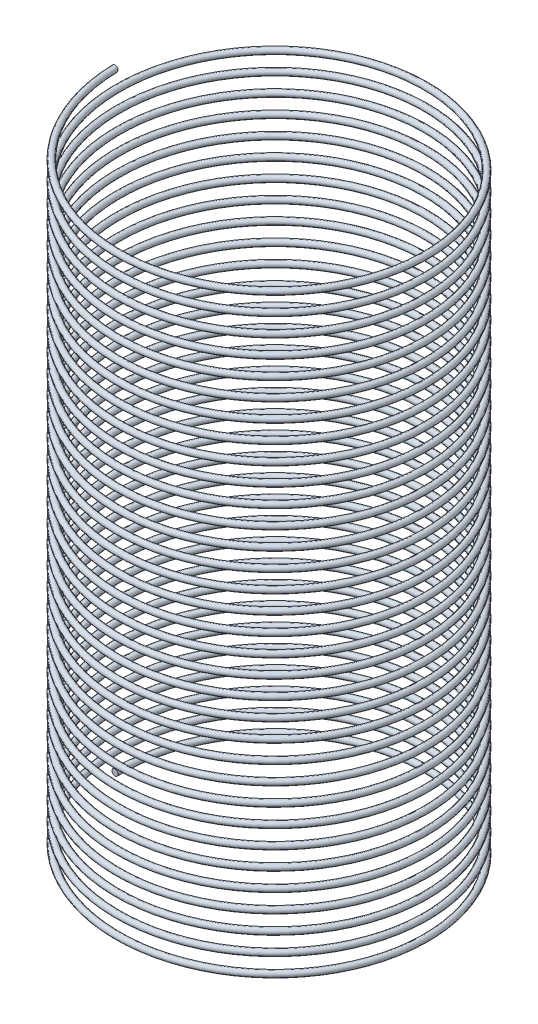
from build123d import *

# Parameters (mm, degrees)
SWEEP1_PITCH       = 3
SWEEP1_HEIGHT      = 99
SWEEP1_RADIUS      = 25
SWEEP1_START_ANGLE = -90
SKETCH4_R          = 0.5


with BuildPart() as part:
    # Sweep1: sweep along a helix
    with BuildLine() as sweep1_path:
        add(Helix(SWEEP1_PITCH, SWEEP1_HEIGHT, SWEEP1_RADIUS, center=(0, 0, 0), direction=(0, 1, 0), lefthand=True, mode=Mode.PRIVATE).rotate(Axis((0, 0, 0), (0, 1, 0)), SWEEP1_START_ANGLE))
    # Sketch4 → Sweep1 (sweep)
    with BuildSketch(Plane.XY):
        with Locations((-25, 0)):
            Circle(SKETCH4_R)
    sweep(path=sweep1_path.line, is_frenet=True)


solid = part.part
